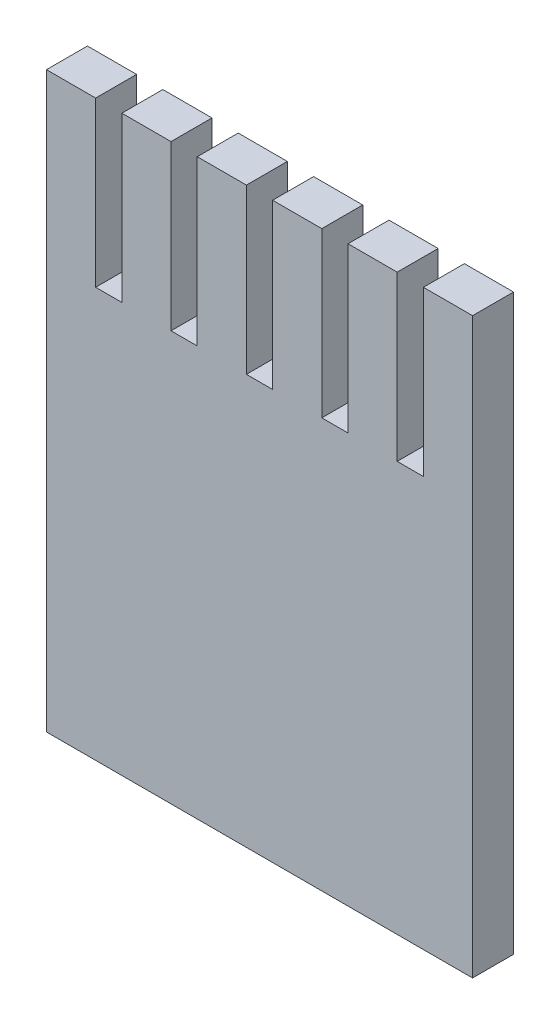
from build123d import *

# Parameters (mm, degrees)
BOSS_EXTRUDE1_DEPTH = 2.5


with BuildPart() as part:
    # Sketch1 → Boss-Extrude1 (new body)
    with BuildSketch(Plane.XY):
        Polygon((0, 35), (0, 0), (26, 0), (26, 35), (23, 35), (23, 25), (21.4, 25), (21.4, 35), (18.4, 35), (18.4, 25), (16.8, 25), (16.8, 35), (13.8, 35), (13.8, 25), (12.2, 25), (12.2, 35), (9.2, 35), (9.2, 25), (7.6, 25), (7.6, 35), (4.6, 35), (4.6, 25), (3, 25), (3, 35), align=None)
    extrude(amount=BOSS_EXTRUDE1_DEPTH)


solid = part.part
